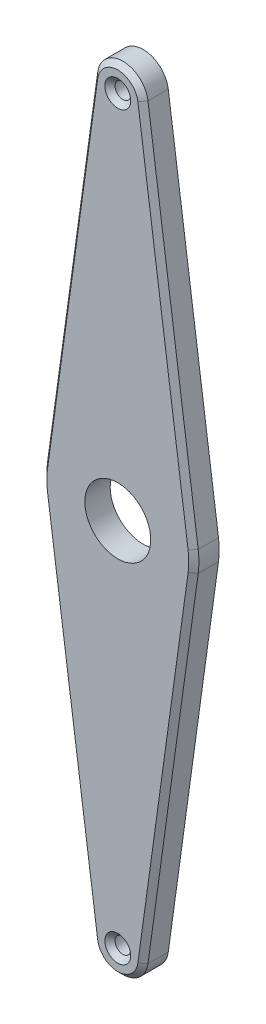
from build123d import *

# Parameters (mm, degrees)
BOSS_EXTRUDE1_DEPTH      = 5
CHAMFER1_SIZE            = 1
CUT_EXTRUDE2_REACH       = 179.034
SKETCH6_R                = 1.55
CHAMFER3_SIZE            = 1
CHAMFER3_OF_MIRROR2_SIZE = 1
CUT_EXTRUDE3_REACH       = 179.034
SKETCH10_R               = 6.5


with BuildPart() as part:
    # Sketch1 → Boss-Extrude1 (new body)
    with BuildSketch(Plane.XY):
        with BuildLine():
            ThreePointArc((99.858594129, 65.945205479), (100, 68), (99.858594129, 70.054794521))
            Line((99.858594129, 70.054794521), (89.95286471, 141.684931507))
            ThreePointArc((89.95286471, 141.684931507), (85, 146), (80.04713529, 141.684931507))
            Line((80.04713529, 141.684931507), (70.141405871, 70.054794521))
            ThreePointArc((70.141405871, 70.054794521), (70, 68), (70.141405871, 65.945205479))
            Line((70.141405871, 65.945205479), (80.04713529, -5.684931507))
            ThreePointArc((80.04713529, -5.684931507), (85, -10), (89.95286471, -5.684931507))
            Line((89.95286471, -5.684931507), (99.858594129, 65.945205479))
        make_face()
    extrude(amount=BOSS_EXTRUDE1_DEPTH)

    # Chamfer1
    chamfer1_edges = [part.edges().sort_by_distance(p)[0] for p in [
        (75.094270581, 30.130136986, 5),
        (70, 68, 5),
        (75.094270581, 105.869863014, 5),
        (85, 146, 5),
        (94.905729419, 105.869863014, 5),
        (100, 68, 5),
        (94.905729419, 30.130136986, 5),
        (85, -10, 5),
    ]]
    chamfer(chamfer1_edges, length=CHAMFER1_SIZE)

    # Sketch6 → Cut-Extrude2 (cut, up to next)
    with BuildSketch(Plane.XY.offset(5), mode=Mode.PRIVATE) as cut_extrude2_sk1:
        with Locations((85, 141)):
            Circle(SKETCH6_R)
    cut_extrude2_tool1 = extrude(cut_extrude2_sk1.sketch, amount=-CUT_EXTRUDE2_REACH, mode=Mode.PRIVATE) & part.part
    cut_extrude2 = cut_extrude2_tool1.solids().sort_by_distance((85, 141, 5))[0]
    add(cut_extrude2, mode=Mode.SUBTRACT)

    # Chamfer3
    chamfer3_edges = [part.edges().sort_by_distance(p)[0] for p in [
        (83.45, 141, 5),
    ]]
    chamfer(chamfer3_edges, length=CHAMFER3_SIZE)

    # Mirror2: Cut-Extrude2 across plane
    add(cut_extrude2.mirror(Plane(origin=(0, 68, 0), x_dir=(0, 0, 1), z_dir=(0, -1, 0))), mode=Mode.SUBTRACT)

    # Chamfer3 of Mirror2
    chamfer3_of_mirror2_edges = [part.edges().sort_by_distance(p)[0] for p in [
        (83.45, -5, 5),
    ]]
    chamfer(chamfer3_of_mirror2_edges, length=CHAMFER3_OF_MIRROR2_SIZE)

    # Sketch10 → Cut-Extrude3 (cut, up to next)
    with BuildSketch(Plane(origin=(0, 0, 0), x_dir=(-1, 0, 0), z_dir=(0, 0, -1)), mode=Mode.PRIVATE) as cut_extrude3_sk1:
        with Locations((-85, 68)):
            Circle(SKETCH10_R)
    cut_extrude3_tool1 = extrude(cut_extrude3_sk1.sketch, amount=-CUT_EXTRUDE3_REACH, mode=Mode.PRIVATE) & part.part
    add(cut_extrude3_tool1.solids().sort_by_distance((85, 68, 0))[0], mode=Mode.SUBTRACT)


solid = part.part
